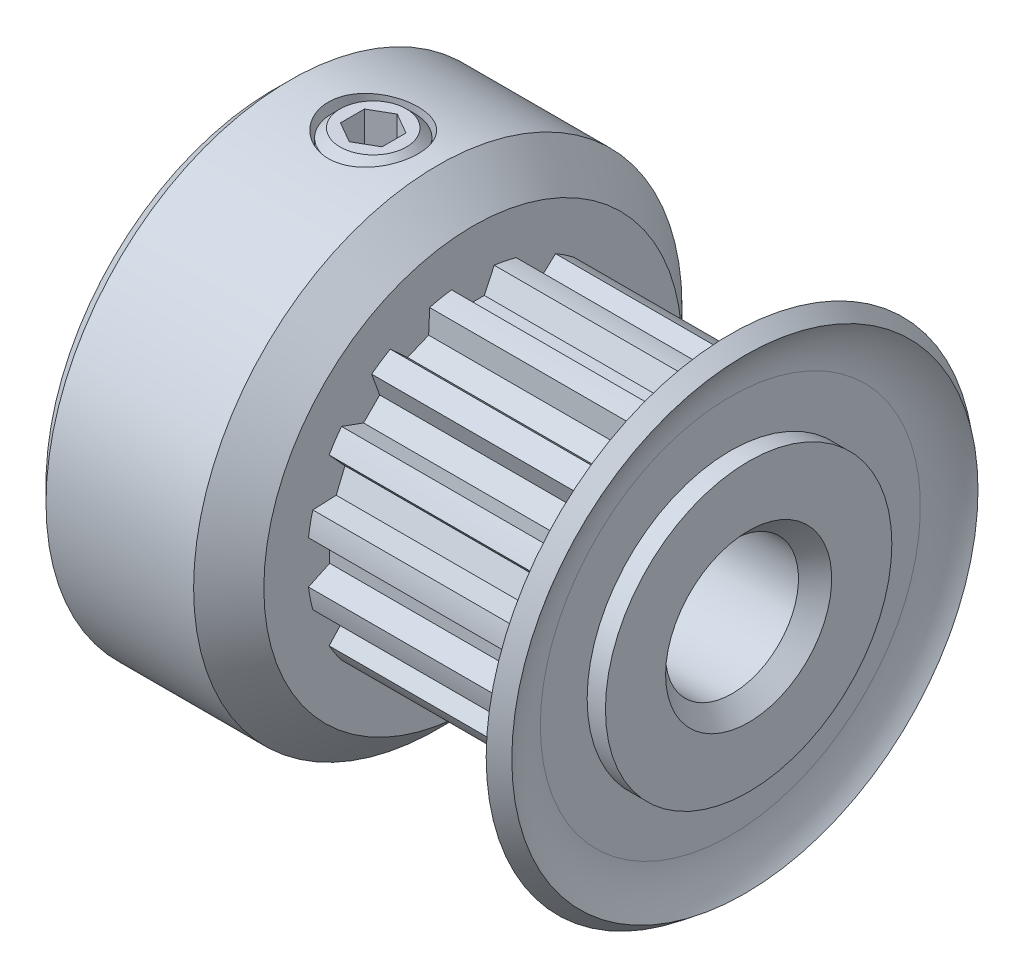
from build123d import *

# Parameters (mm, degrees)
SKETCH4_R          = 5.15
SKETCH4_R_2        = 4.99125
CUT_EXTRUDE2_DEPTH = 7.2
CUT_EXTRUDE1_DEPTH = 7.2
CIRPATTERN1_COUNT  = 16
SKETCH6_R          = 1.35
CUT_EXTRUDE3_DEPTH = 13.616160272
CUT_EXTRUDE4_DEPTH = 1.016
CHAMFER1_SIZE      = 0.5


with BuildPart() as part:
    # Sketch1 → Revolve1 (revolve)
    with BuildSketch(Plane.XY, mode=Mode.PRIVATE) as revolve1_sk:
        with BuildLine():
            Line((-7.15, 2), (7.15, 2))
            Line((7.15, 2), (7.15, 7.35))
            Line((7.15, 7.35), (6.6, 7.35))
            ThreePointArc((6.6, 7.35), (6.191212109, 6.580934734), (6.05, 5.7215))
            Line((6.05, 5.7215), (6.05, 5.15))
            Line((6.05, 5.15), (-1.15, 5.15))
            Line((-1.15, 5.15), (-1.15, 6.293))
            Line((-1.15, 6.293), (-2.207, 7.35))
            Line((-2.207, 7.35), (-7.15, 7.35))
            Line((-7.15, 7.35), (-7.15, 2))
        make_face()
    revolve(revolve1_sk.sketch.rotate(Axis((-7.15, 0, 0), (1, 0, 0)), 90), axis=Axis((-7.15, 0, 0), (1, 0, 0)))

    # Sketch4 → Cut-Extrude2 (cut)
    with BuildSketch(Plane(origin=(-1.15, 0, 0), x_dir=(0, 0, -1), z_dir=(1, 0, 0))):
        Circle(SKETCH4_R)
        Circle(SKETCH4_R_2, mode=Mode.SUBTRACT)
    extrude(amount=CUT_EXTRUDE2_DEPTH, mode=Mode.SUBTRACT)

    # Sketch3 → Cut-Extrude1 (cut)
    with BuildSketch(Plane(origin=(-1.15, 0, 0), x_dir=(0, 0, -1), z_dir=(1, 0, 0))):
        with BuildLine():
            Line((-0.642006023, 4.949788362), (-0.344037701, 4.310793234))
            Line((-0.344037701, 4.310793234), (0.344037701, 4.310793234))
            Line((0.344037701, 4.310793234), (0.642006023, 4.949788362))
            ThreePointArc((0.642006023, 4.949788362), (0, 4.99125), (-0.642006023, 4.949788362))
        make_face()
    cut_extrude1 = extrude(amount=CUT_EXTRUDE1_DEPTH, mode=Mode.SUBTRACT)

    # CirPattern1: Cut-Extrude1 ×16 about axis
    cirpattern1_axis = Axis((0, 0, 0), (1, 0, 0))
    for i in range(1, CIRPATTERN1_COUNT):
        add(cut_extrude1.rotate(cirpattern1_axis, i * 360 / CIRPATTERN1_COUNT), mode=Mode.SUBTRACT)

    # Sketch6 → Cut-Extrude3 (cut, through all)
    with BuildSketch(Plane(origin=(0, 0, 0), x_dir=(1, 0, 0), z_dir=(0, 1, 0))):
        with Locations(Location((-4.15, 0, 0), (0, 0, 90))):
            Circle(SKETCH6_R)
    extrude(amount=CUT_EXTRUDE3_DEPTH, mode=Mode.SUBTRACT)

    # Chamfer1
    chamfer1_edges = [part.edges().sort_by_distance(p)[0] for p in [
        (-7.15, 0, -7.35),
        (-7.15, 0, -2),
        (7.15, 0, -2),
    ]]
    chamfer(chamfer1_edges, length=CHAMFER1_SIZE)

    # Sketch9 → Cut-Revolve1 (revolve, cut)
    with BuildSketch(Plane.XY, mode=Mode.PRIVATE) as cut_revolve1_sk:
        with BuildLine():
            Line((7.15, 4.310793234), (7.15, 7.35))
            Line((7.15, 7.35), (6.802186426, 7.615185187))
            Line((6.802186426, 7.615185187), (6.6, 7.35))
            Line((6.6, 7.35), (7.037375657, 7.01652956))
            ThreePointArc((7.037375657, 7.01652956), (6.712295889, 6.404946967), (6.6, 5.7215))
            Line((6.6, 5.7215), (6.6, 4.310793234))
            Line((6.6, 4.310793234), (7.15, 4.310793234))
        make_face()
    revolve(cut_revolve1_sk.sketch.rotate(Axis((-7.15, 0, 0), (1, 0, 0)), 90), axis=Axis((-7.15, 0, 0), (1, 0, 0)), mode=Mode.SUBTRACT)


with BuildPart() as body_2:
    # Sketch7 → Revolve2 (revolve)
    with BuildSketch(Plane.XY, mode=Mode.PRIVATE) as revolve2_sk:
        Polygon((-5.146, 7.35), (-4.15, 7.35), (-4.15, 2.381), (-5.146, 2.381), (-5.4, 2.635), (-5.4, 7.096), align=None)
    revolve(revolve2_sk.sketch.rotate(Axis((-4.15, 2.381, 0), (0, 1, 0)), 270), axis=Axis((-4.15, 2.381, 0), (0, 1, 0)))

    # Sketch8 → Cut-Extrude4 (cut)
    with BuildSketch(Plane(origin=(0, 7.35, 0), x_dir=(1, 0, 0), z_dir=(0, 1, 0))):
        Polygon((-4.15, 0.721687836), (-4.775, 0.360843918), (-4.775, -0.360843918), (-4.15, -0.721687836), (-3.525, -0.360843918), (-3.525, 0.360843918), align=None)
    extrude(amount=-CUT_EXTRUDE4_DEPTH, mode=Mode.SUBTRACT)


solid = Compound([part.part, body_2.part])
